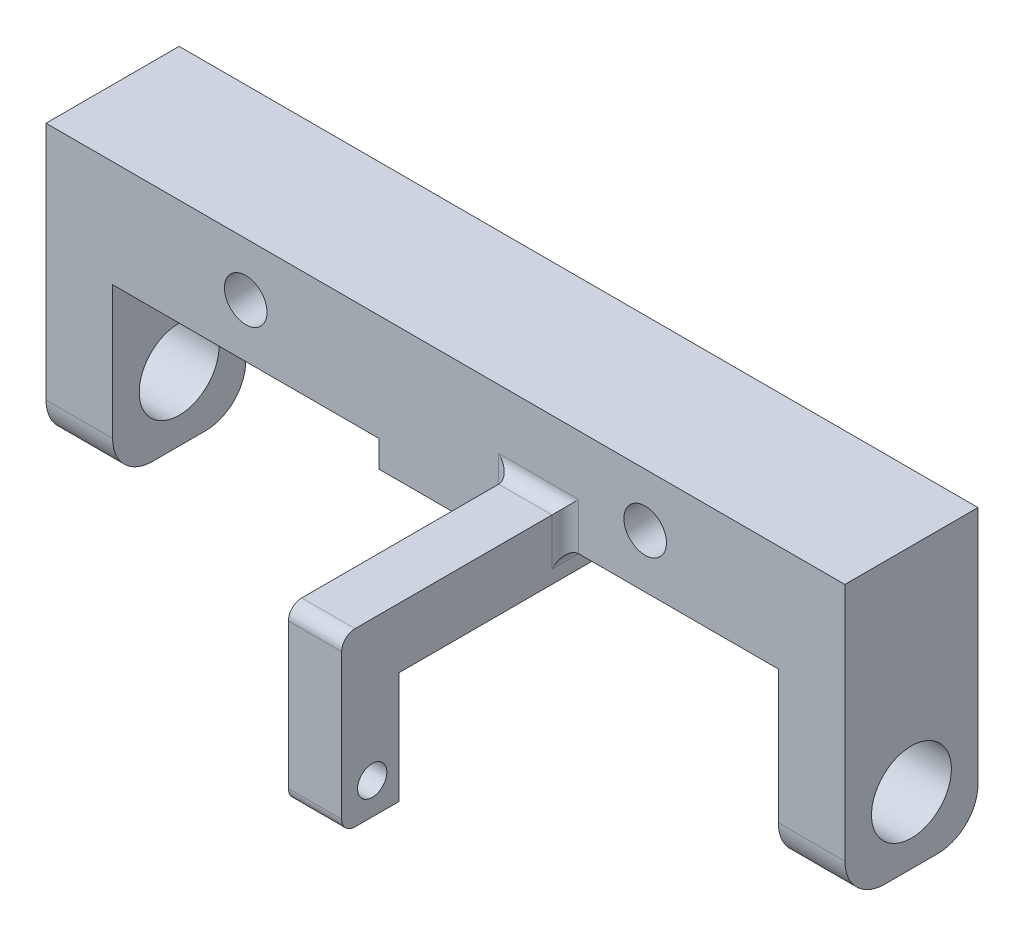
from build123d import *

# Parameters (mm, degrees)
SKETCH_1_W               = 60
SKETCH_1_H               = 10
EXTRUDE_1_DEPTH          = 8
SKETCH_2_W               = 10
SKETCH_2_H               = 21
SKETCH_2_R               = 3
EXTRUDE_2_DEPTH          = 5
FILLET_1_R               = 3
SKETCH_3_R               = 1.1
EXTRUDE_3_DEPTH          = 4
SKETCH_5_W               = 10
SKETCH_5_H               = 2
EXTRUDE_4_DEPTH          = 10
FILLET_4_R               = 1
SKETCH_4_R               = 1.6
CUT_EXTRUDE_1_DEPTH      = 17.792928464
CUT_EXTRUDE_1_DEPTH_BACK = 16.892331711


with BuildPart() as part:
    # 草图1 → 凸台-拉伸1 (new body)
    with BuildSketch(Plane(origin=(0, 0, 0), x_dir=(1, 0, 0), z_dir=(0, 1, 0))):
        Rectangle(SKETCH_1_W, SKETCH_1_H)
    extrude(amount=EXTRUDE_1_DEPTH)

    # 草图2 → 凸台-拉伸2 (add)
    with BuildSketch(Plane(origin=(30, 0, 0), x_dir=(0, 0, -1), z_dir=(1, 0, 0))):
        with Locations((0, -2.5)):
            Rectangle(SKETCH_2_W, SKETCH_2_H)
        with Locations((0, -8)):
            Circle(SKETCH_2_R, mode=Mode.SUBTRACT)
    extrude_2 = extrude(amount=-EXTRUDE_2_DEPTH)

    # 镜向1: 凸台-拉伸2 across plane
    add(extrude_2.mirror(Plane(origin=(0, 0, 0), x_dir=(0, 0, 1), z_dir=(1, 0, 0))))

    # 圆角1
    fillet_1_edges = [part.edges().sort_by_distance(p)[0] for p in [
        (27.5, -13, 5),
        (27.5, -13, -5),
        (-27.5, -13, -5),
        (-27.5, -13, 5),
    ]]
    fillet(fillet_1_edges, radius=FILLET_1_R)

    # 草图3 → 凸台-拉伸3 (add)
    with BuildSketch(Plane.ZY.offset(-5)):
        Polygon((-6.5, -2), (17.5, -2), (17.5, -8), (17.5, -10.376383694), (21.792928464, -10.376383694), (21.792928464, 2.519827065), (-10.892331711, 2.519827065), (-10.892331711, -10.376383694), (-6.5, -10.376383694), (-6.5, -8), align=None)
        with Locations((-8.5, -8)):
            Circle(SKETCH_3_R, mode=Mode.SUBTRACT)
        with Locations((19.5, -8)):
            Circle(SKETCH_3_R, mode=Mode.SUBTRACT)
    extrude(amount=-EXTRUDE_3_DEPTH)

    # 草图5 → 凸台-拉伸4 (add)
    with BuildSketch(Plane.ZY.offset(-5)):
        with Locations((0, -1)):
            Rectangle(SKETCH_5_W, SKETCH_5_H)
    extrude(amount=EXTRUDE_4_DEPTH)

    # 圆角4
    fillet_4_edges = [part.edges().sort_by_distance(p)[0] for p in [
        (5, 0.259913532, -5),
        (7, 2.519827065, -5),
        (9, 1.259913532, -5),
        (7, 2.519827065, -10.892331711),
        (5, 0.259913532, 5),
        (7, -10.376383694, -10.892331711),
        (7, 2.519827065, 5),
        (7, 2.519827065, 21.792928464),
        (7, -10.376383694, 21.792928464),
        (9, 1.259913532, 5),
        (9, 0, 0),
    ]]
    fillet(fillet_4_edges, radius=FILLET_4_R)

    # 草图4 → 切除-拉伸1 (cut, two sides)
    with BuildSketch(Plane.XY.offset(5)) as cut_extrude_1_sk:
        with Locations((-15, 4)):
            Circle(SKETCH_4_R)
        with Locations((15, 4)):
            Circle(SKETCH_4_R)
    extrude(amount=CUT_EXTRUDE_1_DEPTH, mode=Mode.SUBTRACT)
    extrude(cut_extrude_1_sk.sketch, amount=-CUT_EXTRUDE_1_DEPTH_BACK, mode=Mode.SUBTRACT)


solid = part.part
